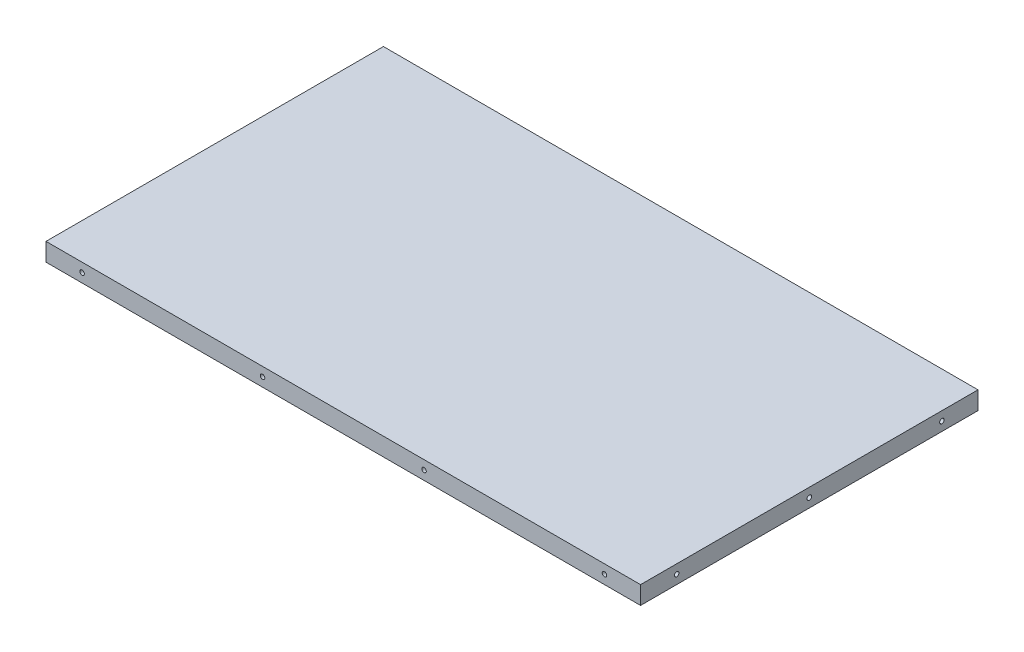
from build123d import *

# Parameters (mm, degrees)
SKETCH1_W           = 329.5
SKETCH1_H           = 187
BOSS_EXTRUDE1_DEPTH = 10
SKETCH2_R           = 1.25
CUT_EXTRUDE1_DEPTH  = 10
CUT_EXTRUDE2_START  = -187
SKETCH2_2_R         = 1.25
CUT_EXTRUDE2_DEPTH  = 10
SKETCH3_R           = 1.25
CUT_EXTRUDE3_DEPTH  = 10
CUT_EXTRUDE4_START  = -329.5
SKETCH3_2_R         = 1.25
CUT_EXTRUDE4_DEPTH  = 10


with BuildPart() as part:
    # Sketch1 → Boss-Extrude1 (new body)
    with BuildSketch(Plane(origin=(0, 0, 0), x_dir=(1, 0, 0), z_dir=(0, 1, 0))):
        with Locations((164.75, 93.5)):
            Rectangle(SKETCH1_W, SKETCH1_H)
    extrude(amount=BOSS_EXTRUDE1_DEPTH)

    # Sketch2 → Cut-Extrude1 (cut)
    with BuildSketch(Plane.XY):
        with Locations((20, 5)):
            Circle(SKETCH2_R)
        with Locations((120, 5)):
            Circle(SKETCH2_R)
        with Locations((209.5, 5)):
            Circle(SKETCH2_R)
        with Locations((309.5, 5)):
            Circle(SKETCH2_R)
    extrude(amount=-CUT_EXTRUDE1_DEPTH, mode=Mode.SUBTRACT)

    # Sketch2_2 → Cut-Extrude2 (cut)
    with BuildSketch(Plane.XY.offset(CUT_EXTRUDE2_START)):
        with Locations((20, 5)):
            Circle(SKETCH2_2_R)
        with Locations((120, 5)):
            Circle(SKETCH2_2_R)
        with Locations((209.5, 5)):
            Circle(SKETCH2_2_R)
        with Locations((309.5, 5)):
            Circle(SKETCH2_2_R)
    extrude(amount=CUT_EXTRUDE2_DEPTH, mode=Mode.SUBTRACT)

    # Sketch3 → Cut-Extrude3 (cut)
    with BuildSketch(Plane.ZY):
        with Locations((-167, 5)):
            Circle(SKETCH3_R)
        with Locations((-93.5, 5)):
            Circle(SKETCH3_R)
        with Locations((-20, 5)):
            Circle(SKETCH3_R)
    extrude(amount=-CUT_EXTRUDE3_DEPTH, mode=Mode.SUBTRACT)

    # Sketch3_2 → Cut-Extrude4 (cut)
    with BuildSketch(Plane.ZY.offset(CUT_EXTRUDE4_START)):
        with Locations((-167, 5)):
            Circle(SKETCH3_2_R)
        with Locations((-93.5, 5)):
            Circle(SKETCH3_2_R)
        with Locations((-20, 5)):
            Circle(SKETCH3_2_R)
    extrude(amount=CUT_EXTRUDE4_DEPTH, mode=Mode.SUBTRACT)


solid = part.part
